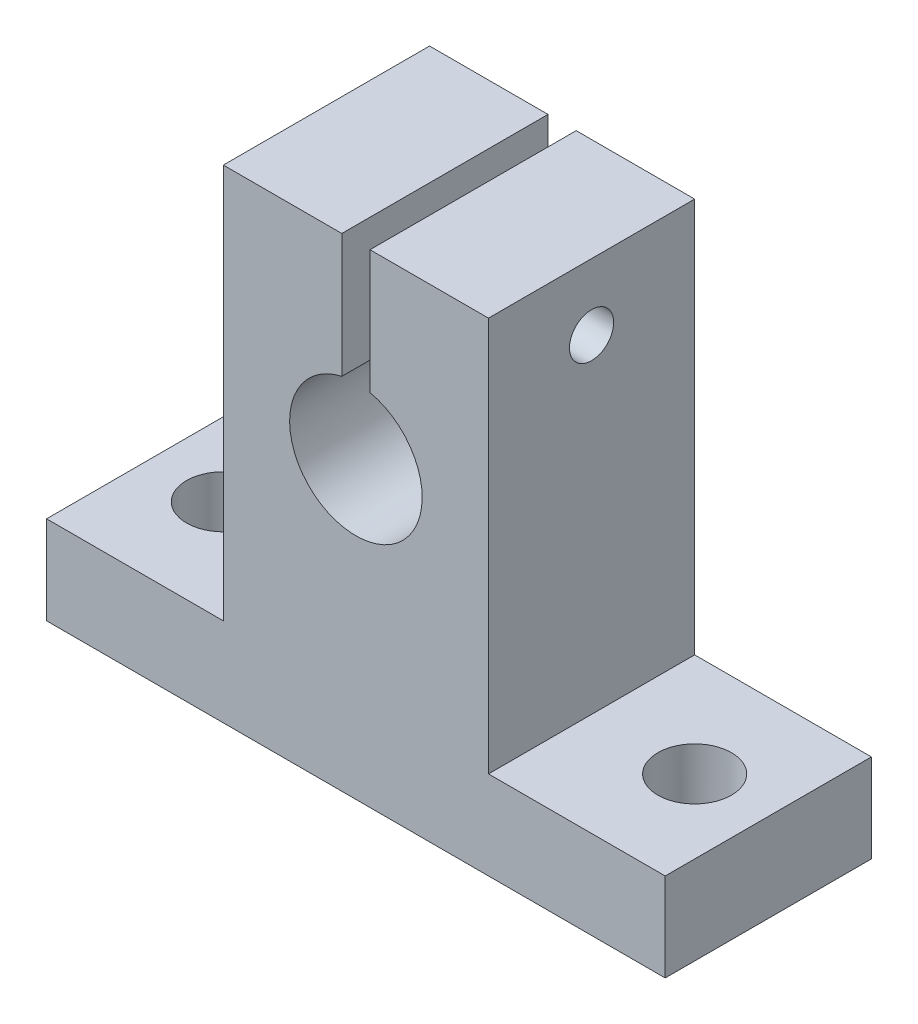
from build123d import *

# Parameters (mm, degrees)
BOSS_EXTRUDE1_DEPTH = 14
CUT_EXTRUDE1_REACH  = 8
SKETCH2_R           = 2.5
SKETCH3_R           = 1.5
CUT_EXTRUDE2_DEPTH  = 31


with BuildPart() as part:
    # Sketch1 → Boss-Extrude1 (new body)
    with BuildSketch(Plane.XY):
        with BuildLine():
            Line((-0.95630186, 29.8), (-0.95630186, 21.397213521))
            ThreePointArc((-0.95630186, 21.397213521), (0, 12.5), (0.95630186, 21.397213521))
            Line((0.95630186, 21.397213521), (0.95630186, 29.8))
            Line((0.95630186, 29.8), (9, 29.8))
            Line((9, 29.8), (9, 3))
            Line((9, 3), (21, 3))
            Line((21, 3), (21, -3))
            Line((21, -3), (-21, -3))
            Line((-21, -3), (-21, 3))
            Line((-21, 3), (-9, 3))
            Line((-9, 3), (-9, 29.8))
            Line((-9, 29.8), (-0.95630186, 29.8))
        make_face()
    extrude(amount=BOSS_EXTRUDE1_DEPTH)

    # Sketch2 → Cut-Extrude1 (cut, up to next)
    with BuildSketch(Plane(origin=(0, 3, 0), x_dir=(1, 0, 0), z_dir=(0, 1, 0)), mode=Mode.PRIVATE) as cut_extrude1_sk1:
        with Locations((-16, -7)):
            Circle(SKETCH2_R)
    cut_extrude1_tool1 = extrude(cut_extrude1_sk1.sketch, amount=-CUT_EXTRUDE1_REACH, mode=Mode.PRIVATE) & part.part
    add(cut_extrude1_tool1.solids().sort_by_distance((-16, 3, 7))[0], mode=Mode.SUBTRACT)
    # Sketch2 → Cut-Extrude1 (cut, up to next)
    with BuildSketch(Plane(origin=(0, 3, 0), x_dir=(1, 0, 0), z_dir=(0, 1, 0)), mode=Mode.PRIVATE) as cut_extrude1_sk2:
        with Locations((16, -7)):
            Circle(SKETCH2_R)
    cut_extrude1_tool2 = extrude(cut_extrude1_sk2.sketch, amount=-CUT_EXTRUDE1_REACH, mode=Mode.PRIVATE) & part.part
    add(cut_extrude1_tool2.solids().sort_by_distance((16, 3, 7))[0], mode=Mode.SUBTRACT)

    # Sketch3 → Cut-Extrude2 (cut, through all)
    with BuildSketch(Plane.ZY.offset(9)):
        with Locations((7, 25.3)):
            Circle(SKETCH3_R)
    extrude(amount=-CUT_EXTRUDE2_DEPTH, mode=Mode.SUBTRACT)


solid = part.part
